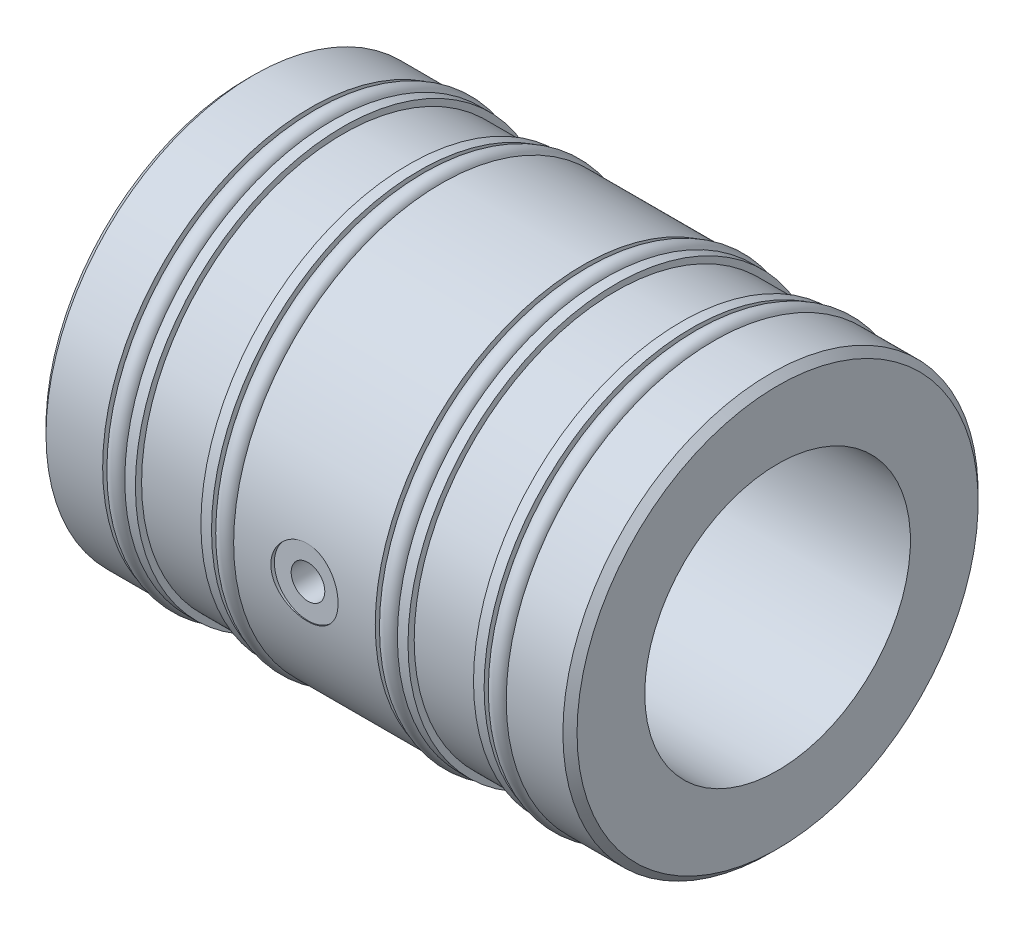
from build123d import *

# Parameters (mm, degrees)
CHAMFER1_SIZE                   = 1.016
F_1_4_0_25_DIAMETER_HOLE1_D     = 9.652
F_1_4_0_25_DIAMETER_HOLE1_DEPTH = 0.508
AIR_HOLE_D                      = 4.0894
AIR_HOLE_DEPTH                  = 6.35
AIR_HOLE_CBORE_D                = 4.826
AIR_HOLE_CBORE_DEPTH            = 5.9944
AIR_HOLE_TIP                    = 1.228579708
SKETCH5_R                       = 1.3081


with BuildPart() as part:
    # Sketch1 → Revolve1 (revolve)
    with BuildSketch(Plane.XY, mode=Mode.PRIVATE) as revolve1_sk:
        Polygon((0, 19.06016), (76.2, 19.06016), (76.2, 29.7942), (67.056, 29.7942), (67.056, 27.813), (63.881, 27.813), (63.881, 29.7942), (62.357, 29.7942), (62.357, 28.9052), (52.959, 28.9052), (52.959, 29.7942), (51.435, 29.7942), (51.435, 27.813), (48.26, 27.813), (48.26, 29.7942), (27.94, 29.7942), (27.94, 27.813), (24.765, 27.813), (24.765, 29.7942), (23.241, 29.7942), (23.241, 28.9052), (13.843, 28.9052), (13.843, 29.7942), (12.319, 29.7942), (12.319, 27.813), (9.144, 27.813), (9.144, 29.7942), (0, 29.7942), align=None)
    revolve(revolve1_sk.sketch.rotate(Axis((0, 0, 0), (1, 0, 0)), 90), axis=Axis((0, 0, 0), (1, 0, 0)))  # turned: the seam where the file's is

    # Chamfer1
    chamfer1_edges = [part.edges().sort_by_distance(p)[0] for p in [
        (76.2, 0, -29.7942),
        (0, 0, -29.7942),
    ]]
    chamfer(chamfer1_edges, length=CHAMFER1_SIZE)

    # 1/4 (0.25) Diameter Hole1
    with Locations(Plane(origin=(38.1, 0, 29.7942), x_dir=(1, 0, 0), z_dir=(0, 0, 1))):
        with Locations((0, 0)):
            Hole(F_1_4_0_25_DIAMETER_HOLE1_D / 2, depth=F_1_4_0_25_DIAMETER_HOLE1_DEPTH)

    # Air Hole
    with Locations(Plane.XY.offset(29.2862)):
        with Locations((38.1, 0)):
            CounterBoreHole(AIR_HOLE_D / 2, AIR_HOLE_CBORE_D / 2, AIR_HOLE_CBORE_DEPTH, depth=AIR_HOLE_DEPTH)
            with Locations((0, 0, -(AIR_HOLE_DEPTH + AIR_HOLE_TIP / 2))):  # 118° drill point
                Cone(0, AIR_HOLE_D / 2, AIR_HOLE_TIP, mode=Mode.SUBTRACT)

    # Sketch5 → Revolve2 (revolve)
    with BuildSketch(Plane.XY, mode=Mode.PRIVATE) as revolve2_sk:
        with Locations((10.7315, 28.9306)):
            Circle(SKETCH5_R)
        with Locations((26.3525, 28.9306)):
            Circle(SKETCH5_R)
        with Locations((49.8475, 28.9306)):
            Circle(SKETCH5_R)
        with Locations((65.4685, 28.9306)):
            Circle(SKETCH5_R)
    revolve(revolve2_sk.sketch.rotate(Axis((0, 0, 0), (1, 0, 0)), 90), axis=Axis((0, 0, 0), (1, 0, 0)))  # turned: the seam where the file's is


solid = part.part
